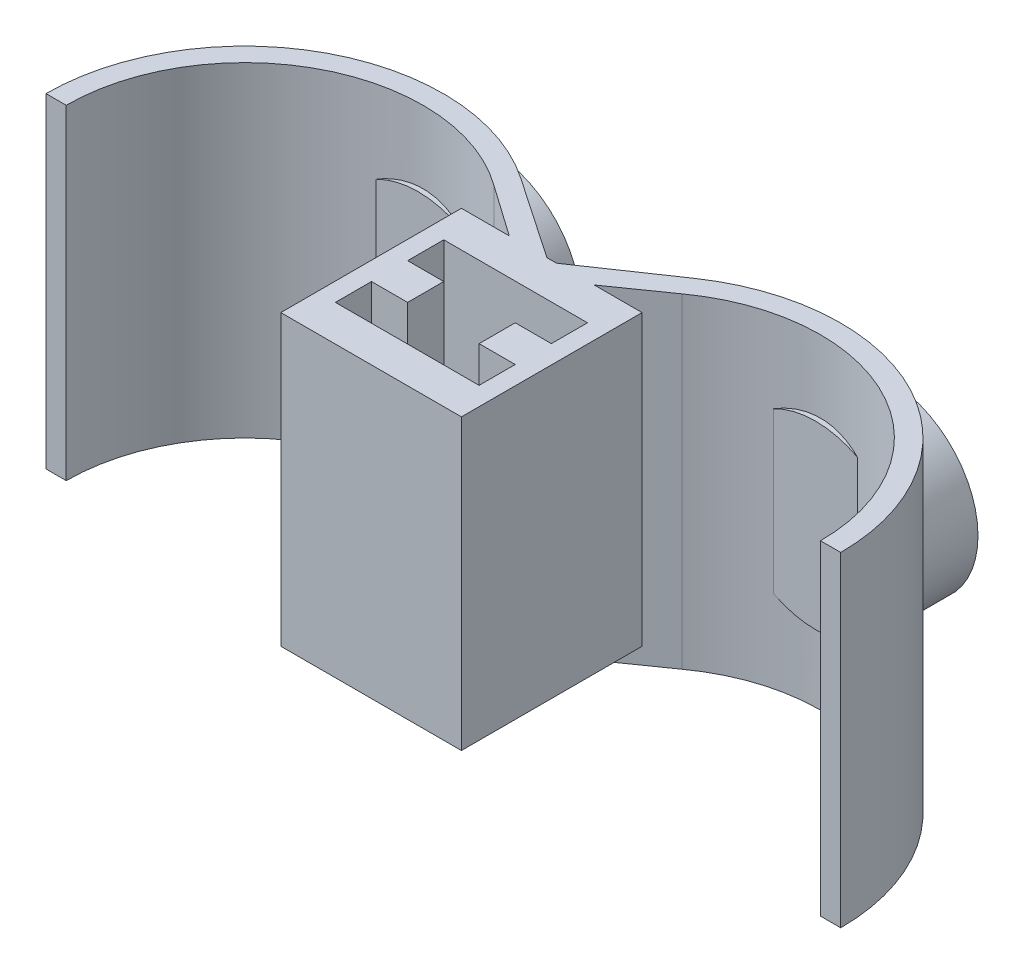
from build123d import *

# Parameters (mm, degrees)
BOSS_EXTRUDE2_DEPTH     = 45
BOSS_EXTRUDE4_START     = -24
SKETCH2_R               = 12.5
BOSS_EXTRUDE4_DEPTH     = 10
BOSS_EXTRUDE6_START     = 10
SKETCH3_W               = 25
SKETCH3_H               = 40
BOSS_EXTRUDE6_DEPTH     = 25
CUT_EXTRUDE1_DEPTH      = 46.0000001
CUT_EXTRUDE1_DEPTH_BACK = 20


with BuildPart() as part:
    # Sketch1 → Boss-Extrude2 (new body)
    with BuildSketch(Plane(origin=(0, 0, 0), x_dir=(1, 0, 0), z_dir=(0, 1, 0))):
        with BuildLine():
            ThreePointArc((-2.801227604, 12.840197836), (-3.388966753, 13.401826964), (-3.866028841, 14.06006427))
            ThreePointArc((-3.866028841, 14.06006427), (-3.636455498, 13.666793472), (-3.413425605, 13.269775202))
            Line((-3.413425605, 13.269775202), (-2.801227604, 12.840197836))
        make_face()
        with BuildLine():
            Line((-4.349767454, 17.506911707), (-12.023106204, 22.731382677))
            ThreePointArc((-12.023106204, 22.731382677), (-7.469700948, 18.842428715), (-3.866028841, 14.06006427))
            ThreePointArc((-3.866028841, 14.06006427), (-4.454774574, 15.734806542), (-4.349767454, 17.506911707))
        make_face()
        with BuildLine():
            Line((-0.844194207, 15.120106399), (-4.349767454, 17.506911707))
            ThreePointArc((-4.349767454, 17.506911707), (-4.454774574, 15.734806542), (-3.866028841, 14.06006427))
            ThreePointArc((-3.866028841, 14.06006427), (-3.388966753, 13.401826964), (-2.801227604, 12.840197836))
            Line((-2.801227604, 12.840197836), (-2.357112674, 12.528563819))
            ThreePointArc((-2.357112674, 12.528563819), (0, 11.861568788), (2.357112674, 12.528563819))
            Line((2.357112674, 12.528563819), (2.801227604, 12.840197836))
            ThreePointArc((2.801227604, 12.840197836), (3.388966727, 13.401826933), (3.8660288, 14.0600642))
            ThreePointArc((3.8660288, 14.0600642), (4.337450172, 15.167351949), (4.498431212, 16.36))
            ThreePointArc((4.498431212, 16.36), (4.461110458, 16.93825327), (4.349767454, 17.506911707))
            Line((4.349767454, 17.506911707), (0.844194207, 15.120106399))
            ThreePointArc((0.844194207, 15.120106399), (0, 14.86), (-0.844194207, 15.120106399))
        make_face()
        with BuildLine():
            Line((12.023106204, 22.731382677), (4.349767454, 17.506911707))
            ThreePointArc((4.349767454, 17.506911707), (4.461110458, 16.93825327), (4.498431212, 16.36))
            ThreePointArc((4.498431212, 16.36), (4.337450172, 15.167351949), (3.8660288, 14.0600642))
            ThreePointArc((3.8660288, 14.0600642), (7.46970092, 18.842428685), (12.023106204, 22.731382677))
        make_face()
        with BuildLine():
            Line((2.801227604, 12.840197836), (3.413425605, 13.269775202))
            ThreePointArc((3.413425605, 13.269775202), (3.636455478, 13.666793437), (3.8660288, 14.0600642))
            ThreePointArc((3.8660288, 14.0600642), (3.388966727, 13.401826933), (2.801227604, 12.840197836))
        make_face()
        with BuildLine():
            Line((52.2, 0), (55, 0))
            ThreePointArc((55, 0), (40.357593488, 24.309098908), (12.023106204, 22.731382677))
            ThreePointArc((12.023106204, 22.731382677), (7.46970092, 18.842428685), (3.8660288, 14.0600642))
            ThreePointArc((3.8660288, 14.0600642), (3.636455478, 13.666793437), (3.413425605, 13.269775202))
            Line((3.413425605, 13.269775202), (13.028813696, 20.016862066))
            ThreePointArc((13.028813696, 20.016862066), (13.312464415, 20.218897943), (13.59893539, 20.416914623))
            ThreePointArc((13.59893539, 20.416914623), (39.048456696, 21.833990655), (52.2, 0))
        make_face()
        with BuildLine():
            ThreePointArc((-12.023106204, 22.731382677), (-40.357593488, 24.309098908), (-55, 0))
            Line((-55, 0), (-52.2, 0))
            ThreePointArc((-52.2, 0), (-39.048456696, 21.833990655), (-13.59893539, 20.416914623))
            ThreePointArc((-13.59893539, 20.416914623), (-13.312464415, 20.218897943), (-13.028813696, 20.016862066))
            Line((-13.028813696, 20.016862066), (-3.413425605, 13.269775202))
            ThreePointArc((-3.413425605, 13.269775202), (-3.636455498, 13.666793472), (-3.866028841, 14.06006427))
            ThreePointArc((-3.866028841, 14.06006427), (-7.469700948, 18.842428715), (-12.023106204, 22.731382677))
        make_face()
    extrude(amount=BOSS_EXTRUDE2_DEPTH)

    # Sketch2 → Boss-Extrude4 (add)
    with BuildSketch(Plane.XY.offset(BOSS_EXTRUDE4_START)):
        with Locations((-27.5, 22.5)):
            Circle(SKETCH2_R)
        with Locations((27.5, 22.5)):
            Circle(SKETCH2_R)
    extrude(amount=-BOSS_EXTRUDE4_DEPTH)

    # Sketch3 → Boss-Extrude6 (add)
    with BuildSketch(Plane.XY.offset(BOSS_EXTRUDE6_START)):
        with Locations((0, 25)):
            Rectangle(SKETCH3_W, SKETCH3_H)
    extrude(amount=-BOSS_EXTRUDE6_DEPTH)

    # Sketch5 → Cut-Extrude1 (cut, two sides)
    with BuildSketch(Plane(origin=(0, 0, 0), x_dir=(1, 0, 0), z_dir=(0, 1, 0))) as cut_extrude1_sk:
        Polygon((-9.94603189, 10), (9.94603189, 10), (9.94603189, 5), (4.94603189, 5), (4.94603189, 0), (9.94603189, 0), (9.94603189, -5), (-9.94603189, -5), (-9.94603189, 0), (-4.94603189, 0), (-4.94603189, 5), (-9.94603189, 5), align=None)
    extrude(amount=CUT_EXTRUDE1_DEPTH, mode=Mode.SUBTRACT)
    extrude(cut_extrude1_sk.sketch, amount=-CUT_EXTRUDE1_DEPTH_BACK, mode=Mode.SUBTRACT)


solid = part.part
